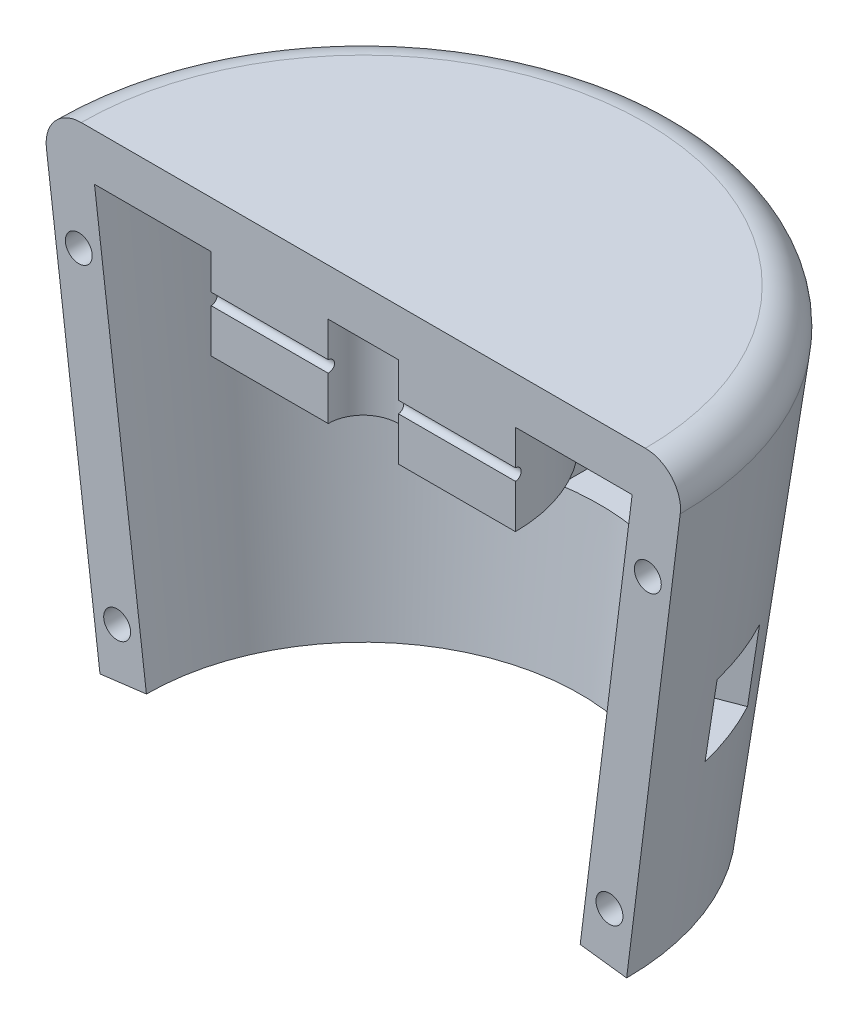
from build123d import *

# Parameters (mm, degrees)
REVOLVE1_ANGLE                  = 180
FILLET1_R                       = 3
SKETCH2_W                       = 30
SKETCH2_H                       = 0.5
SKETCH3_R                       = 1.15
CUT_EXTRUDE1_DEPTH              = 5
SKETCH4_W                       = 7
SKETCH4_H                       = 6.3
CUT_EXTRUDE2_DEPTH              = 3.15
CIRPATTERN1_COUNT               = 2
CIRPATTERN1_ANGLE               = 30
CIRPATTERN1_THE_OTHER_WAY_COUNT = 2
CIRPATTERN1_THE_OTHER_WAY_ANGLE = 30
CIRPATTERN2_COUNT               = 2
CIRPATTERN2_ANGLE               = 69


with BuildPart() as part:
    # Sketch1 → Revolve1 (revolve)
    with BuildSketch(Plane.XY):
        Polygon((0, 40), (-27.5, 40), (-22.5, 0), (-18.530888493, 0.496138938), (-22.968871126, 36), (-13, 36), (-13, 28.277027027), (-3, 28.277027027), (-3, 36), (0, 36), align=None)
    revolve(axis=Axis((0, 40, 0), (0, -1, 0)), revolution_arc=REVOLVE1_ANGLE)

    # Fillet1
    fillet1_edges = [part.edges().sort_by_distance(p)[0] for p in [
        (0, 40, -27.5),
    ]]
    fillet(fillet1_edges, radius=FILLET1_R)

    # Sketch2 → Cut-Revolve1 (revolve, cut)
    with BuildSketch(Plane.XY):
        with Locations((1, 32.75)):
            Rectangle(SKETCH2_W, SKETCH2_H)
    revolve(axis=Axis((-14, 32.5, 0), (1, 0, 0)), mode=Mode.SUBTRACT)

    # Sketch3 → Cut-Extrude1 (cut)
    with BuildSketch(Plane.XY):
        with Locations((-24.309743639, 30.602464611)):
            Circle(SKETCH3_R)
        with Locations((-21.033834323, 4.395190082)):
            Circle(SKETCH3_R)
        with Locations((21.033834323, 4.395190082)):
            Circle(SKETCH3_R)
        with Locations((24.309743639, 30.602464611)):
            Circle(SKETCH3_R)
    extrude(amount=-CUT_EXTRUDE1_DEPTH, mode=Mode.SUBTRACT)

    # Sketch4 → Cut-Extrude2 (cut, symmetric)
    with BuildSketch(Plane(origin=(0, 0, 0), x_dir=(0, 0, -1), z_dir=(1, 0, 0))):
        with Locations((22.970533345, 16.85)):
            Rectangle(SKETCH4_W, SKETCH4_H)
    cut_extrude2 = extrude(amount=CUT_EXTRUDE2_DEPTH, both=True, mode=Mode.SUBTRACT)

    # CirPattern1: Cut-Extrude2 ×2 about axis
    cirpattern1_axis = Axis((0, 36.627895796, 0), (0, -1, 0))
    for i in range(1, CIRPATTERN1_COUNT):
        add(cut_extrude2.rotate(cirpattern1_axis, i * CIRPATTERN1_ANGLE / (CIRPATTERN1_COUNT - 1)), mode=Mode.SUBTRACT)

    # CirPattern1 the other way: Cut-Extrude2 ×2 about axis
    cirpattern1_the_other_way_axis = Axis((0, 36.627895796, 0), (0, 1, 0))
    for i in range(1, CIRPATTERN1_THE_OTHER_WAY_COUNT):
        add(cut_extrude2.rotate(cirpattern1_the_other_way_axis, i * CIRPATTERN1_THE_OTHER_WAY_ANGLE / (CIRPATTERN1_THE_OTHER_WAY_COUNT - 1)), mode=Mode.SUBTRACT)

    # CirPattern2: Cut-Extrude2 ×2 about axis
    cirpattern2_axis = Axis((0, 36.627895796, 0), (0, -1, 0))
    for i in range(1, CIRPATTERN2_COUNT):
        add(cut_extrude2.rotate(cirpattern2_axis, i * CIRPATTERN2_ANGLE / (CIRPATTERN2_COUNT - 1)), mode=Mode.SUBTRACT)


solid = part.part
